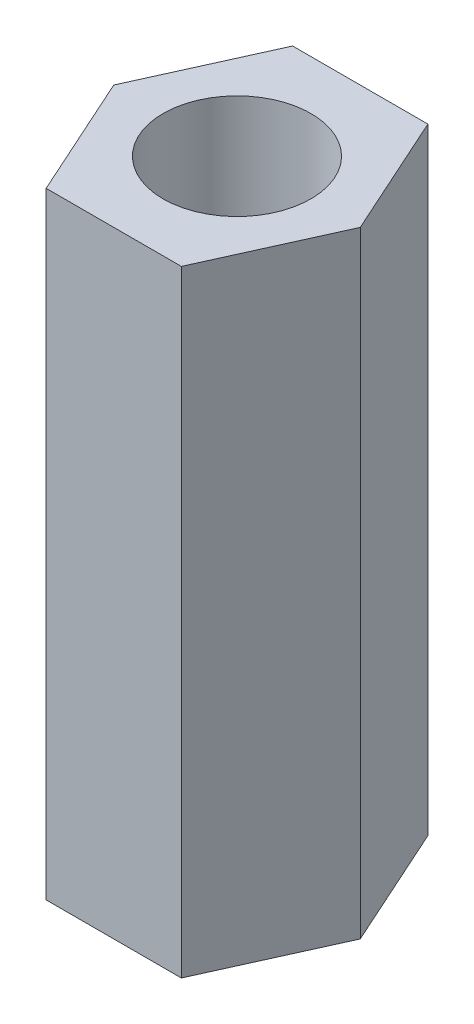
from build123d import *

# Parameters (mm, degrees)
SKETCH1_R      = 3
EXTRUDE1_DEPTH = 25


with BuildPart() as part:
    # Sketch1 → Extrude1 (new body)
    with BuildSketch(Plane(origin=(0, 0, 0), x_dir=(1, 0, 0), z_dir=(0, 1, 0))):
        Polygon((-5, 0), (-2.742918852, 5), (2.742918852, 5), (5, 0), (2.742918852, -5), (-2.742918852, -5), align=None)
        with Locations(Location((0, 0, 0), (0, 0, 270))):  # turned: the seam where the file's is
            Circle(SKETCH1_R, mode=Mode.SUBTRACT)
    extrude(amount=EXTRUDE1_DEPTH)


solid = part.part
